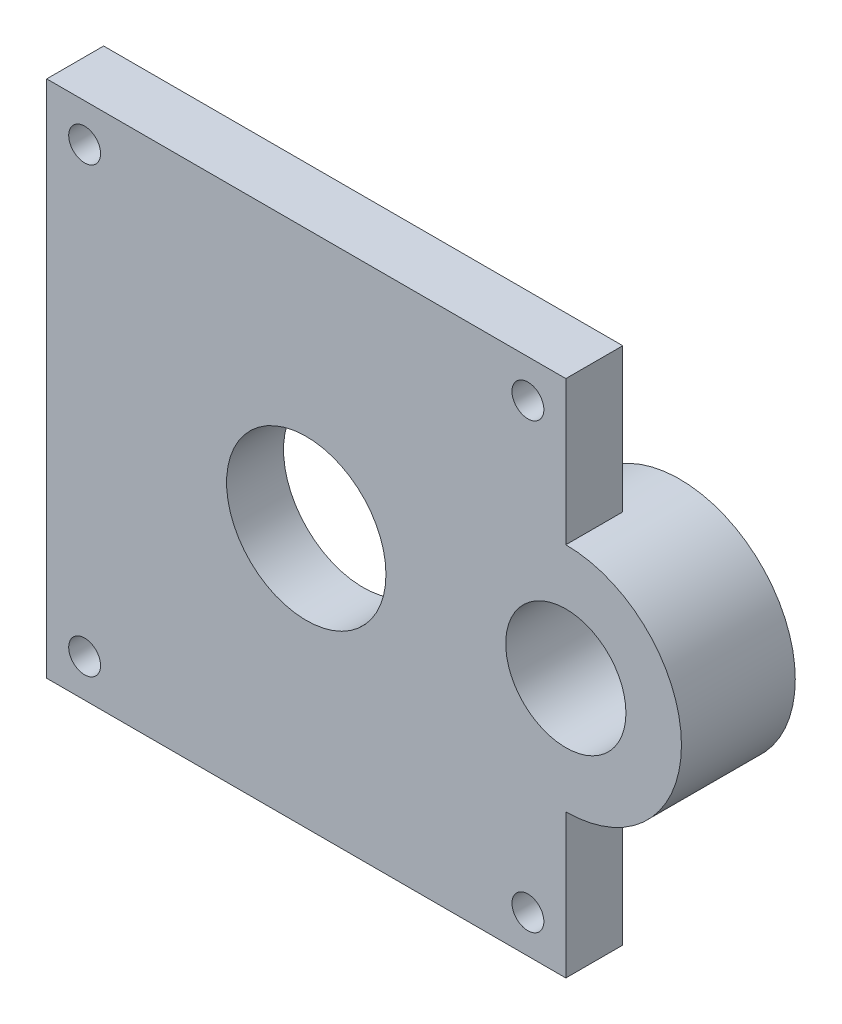
from build123d import *

# Parameters (mm, degrees)
SKETCH1_W           = 28.956
SKETCH1_H           = 28.956
SKETCH1_R           = 4.445
BOSS_EXTRUDE1_DEPTH = 3.175
SKETCH2_R           = 0.889
CUT_EXTRUDE1_DEPTH  = 4.175
SKETCH3_R           = 6.44921875
BOSS_EXTRUDE2_DEPTH = 6.35
SKETCH4_R           = 3.3528
CUT_EXTRUDE2_DEPTH  = 7.35


with BuildPart() as part:
    # Sketch1 → Boss-Extrude1 (new body)
    with BuildSketch(Plane.XY):
        with Locations((14.478, 14.478)):
            Rectangle(SKETCH1_W, SKETCH1_H)
        with Locations((14.478, 14.478)):
            Circle(SKETCH1_R, mode=Mode.SUBTRACT)
    extrude(amount=BOSS_EXTRUDE1_DEPTH)

    # Sketch2 → Cut-Extrude1 (cut, through all)
    with BuildSketch(Plane.XY.offset(3.175)):
        with Locations((2.11455, 2.11455)):
            Circle(SKETCH2_R)
        with Locations((26.84145, 2.11455)):
            Circle(SKETCH2_R)
        with Locations((26.84145, 26.84145)):
            Circle(SKETCH2_R)
        with Locations((2.11455, 26.84145)):
            Circle(SKETCH2_R)
    extrude(amount=-CUT_EXTRUDE1_DEPTH, mode=Mode.SUBTRACT)

    # Sketch3 → Boss-Extrude2 (add)
    with BuildSketch(Plane.XY.offset(3.175)):
        with Locations((28.956, 14.478)):
            Circle(SKETCH3_R)
    extrude(amount=-BOSS_EXTRUDE2_DEPTH)

    # Sketch4 → Cut-Extrude2 (cut, through all)
    with BuildSketch(Plane.XY.offset(3.175)):
        with Locations((28.956, 14.478)):
            Circle(SKETCH4_R)
    extrude(amount=-CUT_EXTRUDE2_DEPTH, mode=Mode.SUBTRACT)


solid = part.part
